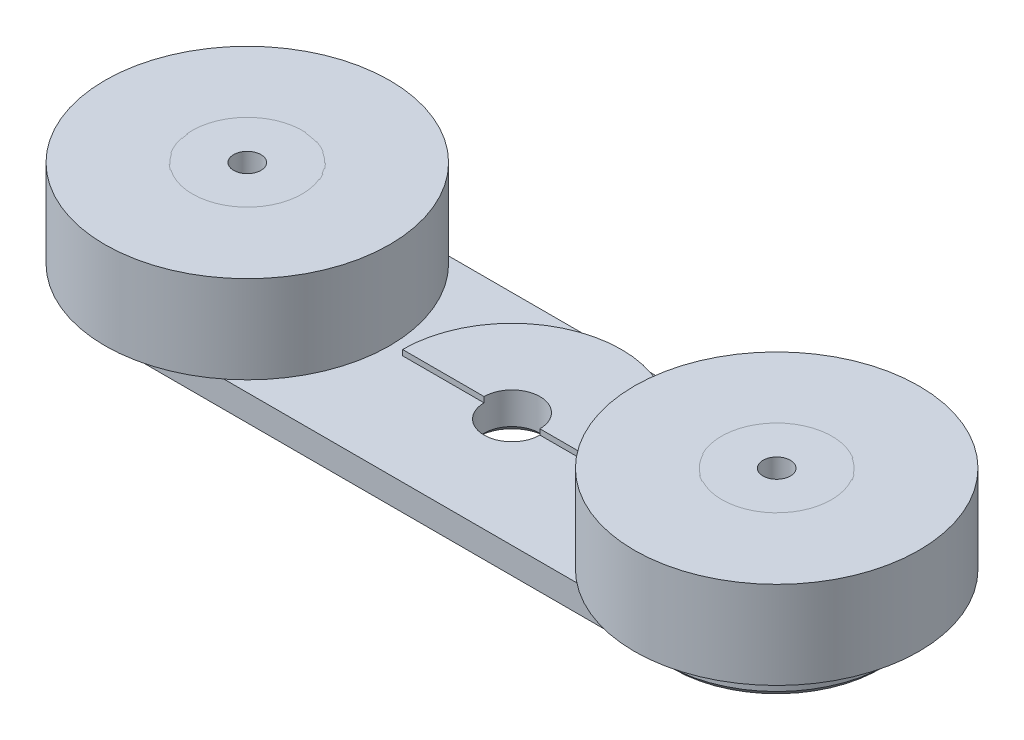
from build123d import *

# Parameters (mm, degrees)
SKETCH1_R            = 2.55
BOSS_EXTRUDE1_DEPTH  = 3
SKETCH10_R           = 7.5
BOSS_EXTRUDE6_DEPTH  = 0.2
SKETCH11_R           = 5.05
BOSS_EXTRUDE8_DEPTH  = 8
SKETCH12_R           = 13
SKETCH12_R_2         = 5
BOSS_EXTRUDE9_DEPTH  = 8
SKETCH13_R           = 1.25
CUT_EXTRUDE6_DEPTH   = 12.2
SKETCH14_R           = 2.55
SKETCH14_R_2         = 1.75
BOSS_EXTRUDE10_DEPTH = 3
SKETCH15_R           = 7.5
SKETCH15_R_2         = 1.75
BOSS_EXTRUDE11_DEPTH = 0.2
CHAMFER1_SIZE        = 2.5
CHAMFER2_SIZE        = 0.6
BOSS_EXTRUDE12_DEPTH = 0.5
BOSS_EXTRUDE13_DEPTH = 0.5
CHAMFER3_SIZE        = 0.6


with BuildPart() as part:
    # Sketch1 → Boss-Extrude1 (new body)
    with BuildSketch(Plane(origin=(0, 0, 0), x_dir=(1, 0, 0), z_dir=(0, 1, 0))):
        with BuildLine():
            Line((24.175, -10), (-24.175, -10))
            ThreePointArc((-24.175, -10), (-34.175, 0), (-24.175, 10))
            Line((-24.175, 10), (24.175, 10))
            ThreePointArc((24.175, 10), (34.175, 0), (24.175, -10))
        make_face()
        Circle(SKETCH1_R, mode=Mode.SUBTRACT)
    extrude(amount=BOSS_EXTRUDE1_DEPTH)

    # Sketch10 → Boss-Extrude6 (add)
    with BuildSketch(Plane(origin=(0, 3, 0), x_dir=(1, 0, 0), z_dir=(0, 1, 0))):
        with Locations((-24.175, 0)):
            Circle(SKETCH10_R)
        with Locations((24.175, 0)):
            Circle(SKETCH10_R)
    extrude(amount=BOSS_EXTRUDE6_DEPTH)

    # Sketch11 → Boss-Extrude8 (add)
    with BuildSketch(Plane(origin=(0, 3.2, 0), x_dir=(1, 0, 0), z_dir=(0, 1, 0))):
        with Locations((-24.175, 0)):
            Circle(SKETCH11_R)
        with Locations((24.175, 0)):
            Circle(SKETCH11_R)
    extrude(amount=BOSS_EXTRUDE8_DEPTH)

    # Sketch13 → Cut-Extrude6 (cut, through all)
    with BuildSketch(Plane(origin=(0, 11.2, 0), x_dir=(1, 0, 0), z_dir=(0, 1, 0))):
        with Locations((-24.175, 0)):
            Circle(SKETCH13_R)
        with Locations((24.175, 0)):
            Circle(SKETCH13_R)
    extrude(amount=-CUT_EXTRUDE6_DEPTH, mode=Mode.SUBTRACT)

    # Sketch16 → Boss-Extrude12 (add)
    with BuildSketch(Plane(origin=(0, 3, 0), x_dir=(1, 0, 0), z_dir=(0, 1, 0))):
        with BuildLine():
            Line((-10, 0), (-2.55, 0))
            ThreePointArc((-2.55, 0), (0, 2.55), (2.55, 0))
            Line((2.55, 0), (10, 0))
            ThreePointArc((10, 0), (0, 10), (-10, 0))
        make_face()
    extrude(amount=BOSS_EXTRUDE12_DEPTH)

    # Chamfer3
    chamfer3_edges = [part.edges().sort_by_distance(p)[0] for p in [
        (-2.55, 0, 0),
        (-25.425, 0, 0),
        (22.925, 0, 0),
        (0, 0, 10),
        (-34.175, 0, 0),
        (0, 0, -10),
        (34.175, 0, 0),
    ]]
    chamfer(chamfer3_edges, length=CHAMFER3_SIZE)


with BuildPart() as body_2:
    # Sketch12 → Boss-Extrude9 (new body)
    with BuildSketch(Plane(origin=(0, 3.2, 0), x_dir=(1, 0, 0), z_dir=(0, 1, 0))):
        with Locations((-24.175, 0)):
            Circle(SKETCH12_R)
        with Locations((-24.175, 0)):
            Circle(SKETCH12_R_2, mode=Mode.SUBTRACT)
    extrude(amount=BOSS_EXTRUDE9_DEPTH)


with BuildPart() as body_3:
    # Mirror3: mirrored copy
    add(body_2.part.mirror(Plane(origin=(0, 0, 0), x_dir=(0, 0, 1), z_dir=(1, 0, 0))))


with BuildPart() as body_4:
    # Sketch14 → Boss-Extrude10 (new body)
    with BuildSketch(Plane(origin=(0, 11.4, 0), x_dir=(1, 0, 0), z_dir=(0, 1, 0))):
        with BuildLine():
            Line((-24.175, -10), (24.175, -10))
            ThreePointArc((24.175, -10), (34.175, 0), (24.175, 10))
            Line((24.175, 10), (-24.175, 10))
            ThreePointArc((-24.175, 10), (-34.175, 0), (-24.175, -10))
        make_face()
        Circle(SKETCH14_R, mode=Mode.SUBTRACT)
        with Locations((-24.175, 0)):
            Circle(SKETCH14_R_2, mode=Mode.SUBTRACT)
        with Locations((24.175, 0)):
            Circle(SKETCH14_R_2, mode=Mode.SUBTRACT)
    extrude(amount=BOSS_EXTRUDE10_DEPTH)

    # Sketch15 → Boss-Extrude11 (add)
    with BuildSketch(Plane.XZ.offset(-11.4)):
        with Locations((24.175, 0)):
            Circle(SKETCH15_R)
        with Locations((24.175, 0)):
            Circle(SKETCH15_R_2, mode=Mode.SUBTRACT)
        with Locations((-24.175, 0)):
            Circle(SKETCH15_R)
        with Locations((-24.175, 0)):
            Circle(SKETCH15_R_2, mode=Mode.SUBTRACT)
    extrude(amount=BOSS_EXTRUDE11_DEPTH)

    # Chamfer1
    chamfer1_edges = [body_4.edges().sort_by_distance(p)[0] for p in [
        (-25.925, 14.4, 0),
        (22.425, 14.4, 0),
    ]]
    chamfer(chamfer1_edges, length=CHAMFER1_SIZE)

    # Chamfer2
    chamfer2_edges = [body_4.edges().sort_by_distance(p)[0] for p in [
        (-34.175, 14.4, 0),
        (-2.55, 14.4, 0),
        (0, 14.4, 10),
        (34.175, 14.4, 0),
        (0, 14.4, -10),
    ]]
    chamfer(chamfer2_edges, length=CHAMFER2_SIZE)

    # Sketch17 → Boss-Extrude13 (add)
    with BuildSketch(Plane.XZ.offset(-11.4)):
        with BuildLine():
            Line((-2.55, 0), (-10, 0))
            ThreePointArc((-10, 0), (0, -10), (10, 0))
            Line((10, 0), (2.55, 0))
            ThreePointArc((2.55, 0), (0, -2.55), (-2.55, 0))
        make_face()
    extrude(amount=BOSS_EXTRUDE13_DEPTH)


solid = Compound([part.part, body_2.part, body_3.part])
